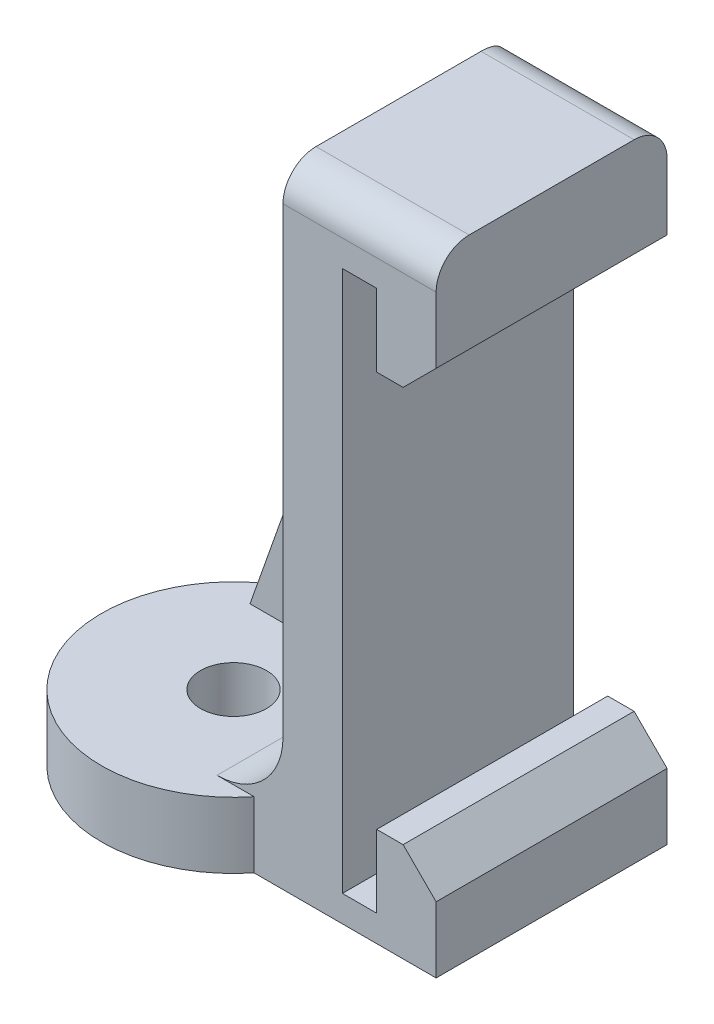
from build123d import *

# Parameters (mm, degrees)
BOSS_EXTRUDE1_DEPTH = 9.525
FILLET1_R           = 3.175
BOSS_EXTRUDE2_DEPTH = 1.5875
SKETCH3_R           = 1.5875
CUT_EXTRUDE1_DEPTH  = 3.175
CHAMFER1_SIZE       = 1.5875
FILLET2_R           = 1.5875
CUT_EXTRUDE2_DEPTH  = 12.7
FILLET3_R           = 1.5875
SKETCH5_R           = 6.35
SKETCH5_R_2         = 1.5875
BOSS_EXTRUDE3_DEPTH = 3.175


with BuildPart() as part:
    # Sketch1 → Boss-Extrude1 (new body, symmetric)
    with BuildSketch(Plane.XY):
        Polygon((-0.3175, -0.3175), (-0.3175, 25.7175), (1.3335, 25.7175), (1.3335, 22.225), (4.191, 22.225), (4.191, 28.575), (1.016, 28.575), (-3.175, 28.575), (-3.175, 1.5875), (-12.7, 1.5875), (-12.7, -1.5875), (-3.175, -1.5875), (4.191, -1.5875), (4.191, 0), (4.191, 3.175), (1.3335, 3.175), (1.3335, -0.3175), align=None)
    extrude(amount=BOSS_EXTRUDE1_DEPTH, both=True)

    # Fillet1
    fillet1_edges = [part.edges().sort_by_distance(p)[0] for p in [
        (-3.175, 1.5875, 0),
    ]]
    fillet(fillet1_edges, radius=FILLET1_R)

    # Sketch2 → Boss-Extrude2 (add, symmetric)
    with BuildSketch(Plane.XY):
        Polygon((-3.175, 28.575), (-12.7, 1.5875), (-3.175, 1.5875), align=None)
    extrude(amount=BOSS_EXTRUDE2_DEPTH, both=True)

    # Sketch3 → Cut-Extrude1 (cut)
    with BuildSketch(Plane(origin=(0, 1.5875, 0), x_dir=(1, 0, 0), z_dir=(0, 1, 0))):
        with Locations((-9.525, -5.55625)):
            Circle(SKETCH3_R)
        with Locations((-9.525, 5.55625)):
            Circle(SKETCH3_R)
    extrude(amount=-CUT_EXTRUDE1_DEPTH, mode=Mode.SUBTRACT)

    # Chamfer1
    chamfer1_edges = [part.edges().sort_by_distance(p)[0] for p in [
        (4.191, 3.175, 0),
        (4.191, 22.225, 0),
    ]]
    chamfer(chamfer1_edges, length=CHAMFER1_SIZE)

    # Fillet2
    fillet2_edges = [part.edges().sort_by_distance(p)[0] for p in [
        (0.508, 28.575, -9.525),
        (0.508, 28.575, 9.525),
    ]]
    fillet(fillet2_edges, radius=FILLET2_R)

    # Sketch4 → Cut-Extrude2 (cut)
    with BuildSketch(Plane(origin=(0, 0, -1.5875), x_dir=(-1, 0, 0), z_dir=(0, 0, -1))):
        Polygon((12.7, 1.5875), (3.175, 28.575), (-4.191, 28.575), (-4.191, -1.5875), (12.7, -1.5875), align=None)
    extrude(amount=CUT_EXTRUDE2_DEPTH, mode=Mode.SUBTRACT)

    # Fillet3
    fillet3_edges = [part.edges().sort_by_distance(p)[0] for p in [
        (0.508, 28.575, -1.5875),
    ]]
    fillet(fillet3_edges, radius=FILLET3_R)

    # Sketch5 → Boss-Extrude3 (add)
    with BuildSketch(Plane(origin=(0, 1.5875, 0), x_dir=(1, 0, 0), z_dir=(0, 1, 0))):
        with Locations((-9.525, -5.55625)):
            Circle(SKETCH5_R)
        with Locations((-9.525, -5.55625)):
            Circle(SKETCH5_R_2, mode=Mode.SUBTRACT)
    extrude(amount=-BOSS_EXTRUDE3_DEPTH)


solid = part.part
